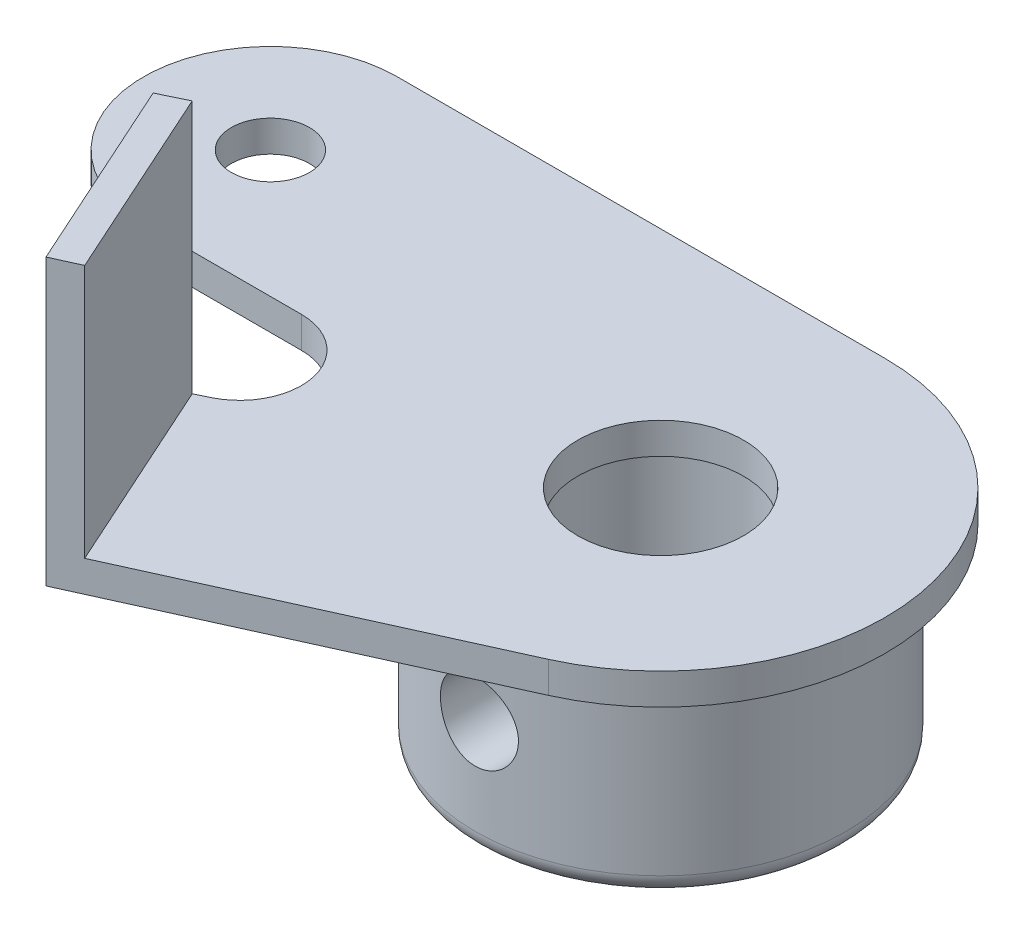
from build123d import *

# Parameters (mm, degrees)
ESQUISSE1_R             = 4.25
ESQUISSE1_R_2           = 2
BOSS_EXTRU_1_DEPTH      = 1.6
ESQUISSE2_R             = 9.5
ESQUISSE2_R_2           = 4.5
BOSS_EXTRU_2_DEPTH      = 11.5
CONG_1_R                = 1
BOSS_EXTRU_3_DEPTH      = 13
ESQUISSE4_R             = 2
ENL_V_MAT_EXTRU_1_DEPTH = 19.5


with BuildPart() as part:
    # Esquisse1 → Boss.-Extru.1 (new body)
    with BuildSketch(Plane(origin=(0, 0, 0), x_dir=(1, 0, 0), z_dir=(0, 1, 0))):
        with BuildLine():
            Line((0, 11.5), (-25, 11.5))
            ThreePointArc((-25, 11.5), (-31.5, 5), (-25, -1.5))
            Line((-25, -1.5), (-16.90921754, -1.5))
            ThreePointArc((-16.90921754, -1.5), (-13.826301978, -3.956560509), (-15.532463951, -7.510159982))
            Line((-15.532463951, -7.510159982), (-17.532463951, -8.477187494))
            Line((-17.532463951, -8.477187494), (-13, -18.5))
            Line((-13, -18.5), (4.73848504, -10.478394893))
            ThreePointArc((4.73848504, -10.478394893), (11.241697854, 2.423680954), (0, 11.5))
        make_face()
        Circle(ESQUISSE1_R, mode=Mode.SUBTRACT)
        with Locations((-25, 5)):
            Circle(ESQUISSE1_R_2, mode=Mode.SUBTRACT)
    extrude(amount=BOSS_EXTRU_1_DEPTH)

    # Esquisse2 → Boss.-Extru.2 (add)
    with BuildSketch(Plane(origin=(0, 1.6, 0), x_dir=(1, 0, 0), z_dir=(0, 1, 0))):
        Circle(ESQUISSE2_R)
        Circle(ESQUISSE2_R_2, mode=Mode.SUBTRACT)
    extrude(amount=-BOSS_EXTRU_2_DEPTH)

    # Congé1
    cong_1_edges = [part.edges().sort_by_distance(p)[0] for p in [
        (-9.5, -9.9, 0),
    ]]
    fillet(cong_1_edges, radius=CONG_1_R)

    # Esquisse3 → Boss.-Extru.3 (add)
    with BuildSketch(Plane(origin=(0, 1.6, 0), x_dir=(1, 0, 0), z_dir=(0, 1, 0))):
        Polygon((-17.532463951, -8.477187494), (-13, -18.5), (-11.633703391, -17.88214048), (-16.182035998, -7.824237002), align=None)
    extrude(amount=BOSS_EXTRU_3_DEPTH)

    # Esquisse4 → Enlèv. mat.-Extru.1 (cut, through all)
    with BuildSketch(Plane.XY):
        with Locations((0, -4)):
            Circle(ESQUISSE4_R)
    extrude(amount=ENL_V_MAT_EXTRU_1_DEPTH, mode=Mode.SUBTRACT)


solid = part.part
